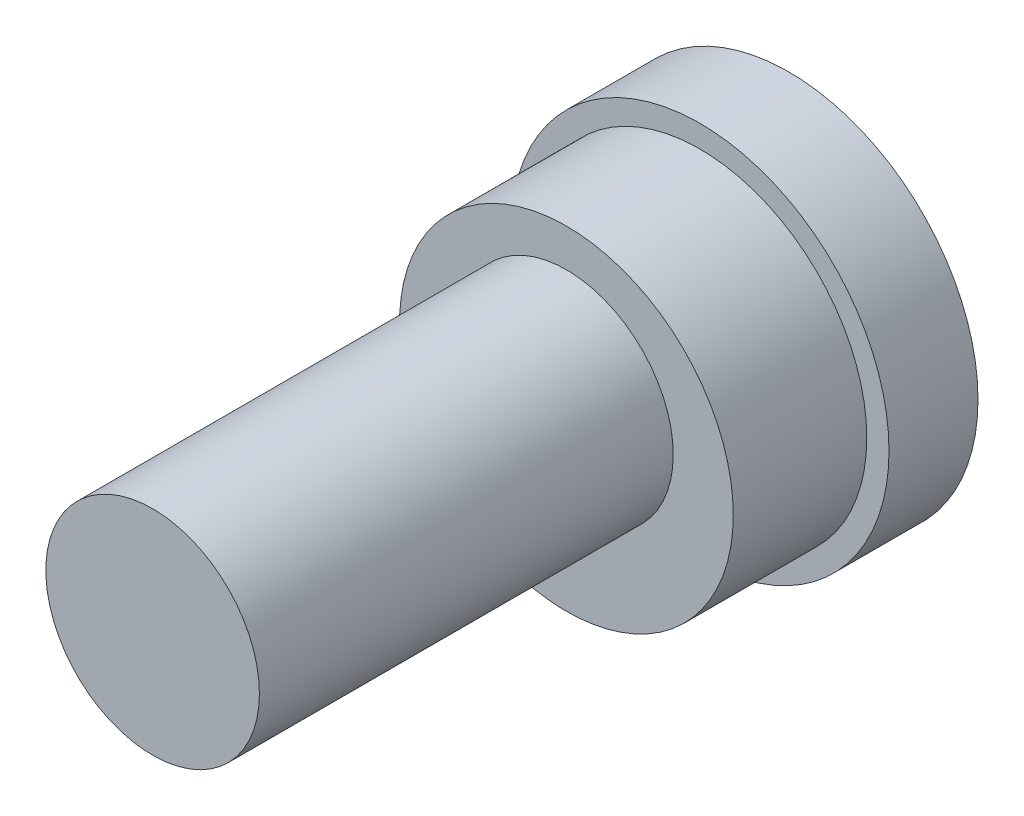
from build123d import *

# Parameters (mm, degrees)
SKETCH_1_R      = 42.5
EXTRUDE_1_DEPTH = 20
SKETCH_2_R      = 37.5
EXTRUDE_2_DEPTH = 30
SKETCH_3_R      = 24
EXTRUDE_3_DEPTH = 93


with BuildPart() as part:
    # ｽｹｯﾁ1 → ﾎﾞｽ - 押し出し1 (new body)
    with BuildSketch(Plane.XY):
        Circle(SKETCH_1_R)
    extrude(amount=EXTRUDE_1_DEPTH)

    # ｽｹｯﾁ2 → ﾎﾞｽ - 押し出し2 (add)
    with BuildSketch(Plane.XY.offset(20)):
        Circle(SKETCH_2_R)
    extrude(amount=EXTRUDE_2_DEPTH)

    # ｽｹｯﾁ3 → ﾎﾞｽ - 押し出し3 (add)
    with BuildSketch(Plane.XY.offset(50)):
        with Locations((0, 5)):
            Circle(SKETCH_3_R)
    extrude(amount=EXTRUDE_3_DEPTH)


solid = part.part
